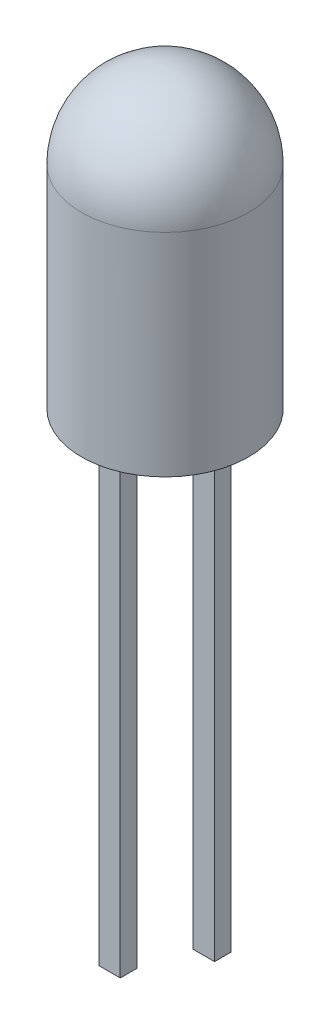
from build123d import *

# Parameters (mm, degrees)
SKETCH3_W             = 0.383062026
SKETCH3_H             = 0.298484562
BOSS_EXTRUDE1_DEPTH   = 8
BOSS_EXTRUDE1_2_DEPTH = 8
BOSS_EXTRUDE2_DEPTH   = 0.15
SKETCH5_R             = 0.189425794
BOSS_EXTRUDE3_DEPTH   = 0.1
SKETCH7_W             = 0.383062026
SKETCH7_H             = 0.298484562
BOSS_EXTRUDE5_DEPTH   = 1.1


with BuildPart() as part:
    # Sketch1 → Revolve1 (revolve)
    with BuildSketch(Plane.XY):
        with BuildLine():
            Line((0, 0), (-1.5, 0))
            Line((-1.5, 0), (-1.5, 3.8))
            ThreePointArc((-1.5, 3.8), (-1.060660172, 4.860660172), (0, 5.3))
            Line((0, 5.3), (0, 0))
        make_face()
    revolve(axis=Axis((0, 0, 0), (0, 1, 0)))


with BuildPart() as body_2:
    # Sketch3 → Boss-Extrude1 (new body)
    with BuildSketch(Plane.XZ):
        with Locations((-0.846347528, 0)):
            Rectangle(SKETCH3_W, SKETCH3_H)
    extrude(amount=BOSS_EXTRUDE1_DEPTH)


with BuildPart() as body_3:
    # Sketch3 → Boss-Extrude1 2 (new body)
    with BuildSketch(Plane.XZ):
        with Locations((0.846347528, 0)):
            Rectangle(SKETCH3_W, SKETCH3_H)
    extrude(amount=BOSS_EXTRUDE1_2_DEPTH)


    add(body_2.part)  # Boss-Extrude2 merges body 2
    # Sketch4 → Boss-Extrude2 (add, symmetric)
    with BuildSketch(Plane.XY):
        Polygon((1.037878541, 2.260445566), (0.294117621, 2.788795467), (0.235969658, 2.706940276), (-0.385685641, 2.706940276), (-0.512741887, 2.796720697), (-0.565939225, 2.796720697), (-0.565939225, 2.617159855), (-0.565939225, 2.418450997), (0.654816515, 1.551255429), (0.654816515, 0), (1.037878541, 0), (1.037878541, 1.551255429), align=None)
        Polygon((0.482142428, 1.551255429), (-0.665939225, 2.366825071), (-0.665939225, 2.617159855), (-1.037878541, 2.617159855), (-1.037878541, 1.551255429), (-1.037878541, 0), (-0.654816515, 0), (-0.654816515, 1.551255429), align=None)
    extrude(amount=BOSS_EXTRUDE2_DEPTH, both=True)

    # Sketch7 → Boss-Extrude5 (add)
    with BuildSketch(Plane.XZ.offset(8)):
        with Locations((-0.846347528, 0)):
            Rectangle(SKETCH7_W, SKETCH7_H)
    extrude(amount=BOSS_EXTRUDE5_DEPTH)


with BuildPart() as body_3_2:
    # Sketch5 → Boss-Extrude3 (new body)
    with BuildSketch(Plane(origin=(0, 2.706940276, 0), x_dir=(1, 0, 0), z_dir=(0, 1, 0))):
        with Locations((-0.060559566, 0)):
            Circle(SKETCH5_R)
    extrude(amount=BOSS_EXTRUDE3_DEPTH)


solid = Compound([part.part, body_3.part, body_3_2.part])
